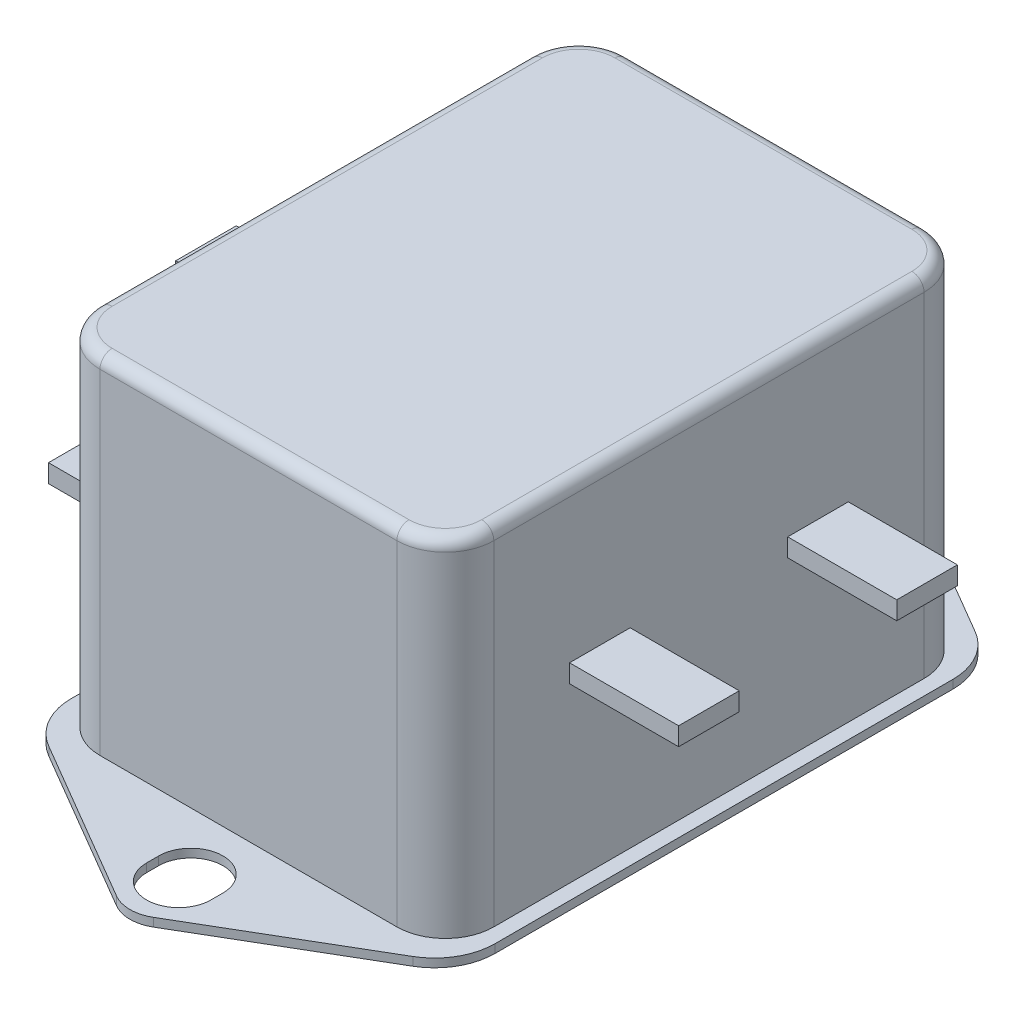
from build123d import *

# Parameters (mm, degrees)
BOSS_EXTRUDE1_DEPTH = 0.7
BOSS_EXTRUDE2_DEPTH = 28.6
SKETCH3_W           = 5
SKETCH3_H           = 1.5
BOSS_EXTRUDE3_DEPTH = 9
SKETCH4_W           = 5
SKETCH4_H           = 1.5
BOSS_EXTRUDE4_DEPTH = 9
FILLET1_R           = 1


with BuildPart() as part:
    # Sketch1 → Boss-Extrude1 (new body)
    with BuildSketch(Plane(origin=(0, 0, 0), x_dir=(1, 0, 0), z_dir=(0, 1, 0))):
        with BuildLine():
            Line((-17.5, 0), (-17.5, 18.884045511))
            ThreePointArc((-17.5, 18.884045511), (-16.837918728, 21.370501041), (-15.027015558, 23.198462316))
            Line((-15.027015558, 23.198462316), (-1.516209335, 31.111934533))
            ThreePointArc((-1.516209335, 31.111934533), (0, 31.523284449), (1.516209335, 31.111934533))
            Line((1.516209335, 31.111934533), (15.027015558, 23.198462316))
            ThreePointArc((15.027015558, 23.198462316), (16.837918728, 21.370501041), (17.5, 18.884045511))
            Line((17.5, 18.884045511), (17.5, 0))
            Line((17.5, 0), (17.5, -18.884045511))
            ThreePointArc((17.5, -18.884045511), (16.837918728, -21.370501041), (15.027015558, -23.198462316))
            Line((15.027015558, -23.198462316), (1.516209335, -31.111934533))
            ThreePointArc((1.516209335, -31.111934533), (0, -31.523284449), (-1.516209335, -31.111934533))
            Line((-1.516209335, -31.111934533), (-15.027015558, -23.198462316))
            ThreePointArc((-15.027015558, -23.198462316), (-16.837918728, -21.370501041), (-17.5, -18.884045511))
            Line((-17.5, -18.884045511), (-17.5, 0))
        make_face()
        with BuildLine():
            Line((2.65, 27.5), (2.65, 26.5))
            ThreePointArc((2.65, 26.5), (0, 23.85), (-2.65, 26.5))
            Line((-2.65, 26.5), (-2.65, 27.5))
            ThreePointArc((-2.65, 27.5), (0, 30.15), (2.65, 27.5))
        make_face(mode=Mode.SUBTRACT)
        with BuildLine():
            Line((2.65, -26.5), (2.65, -27.5))
            ThreePointArc((2.65, -27.5), (0, -30.15), (-2.65, -27.5))
            Line((-2.65, -27.5), (-2.65, -26.5))
            ThreePointArc((-2.65, -26.5), (0, -23.85), (2.65, -26.5))
        make_face(mode=Mode.SUBTRACT)
    extrude(amount=BOSS_EXTRUDE1_DEPTH)

    # Sketch2 → Boss-Extrude2 (add)
    with BuildSketch(Plane(origin=(0, 0.7, 0), x_dir=(1, 0, 0), z_dir=(0, 1, 0))):
        with BuildLine():
            Line((-12.25, 21.75), (12.25, 21.75))
            ThreePointArc((12.25, 21.75), (15.078427125, 20.578427125), (16.25, 17.75))
            Line((16.25, 17.75), (16.25, -17.75))
            ThreePointArc((16.25, -17.75), (15.078427125, -20.578427125), (12.25, -21.75))
            Line((12.25, -21.75), (-12.25, -21.75))
            ThreePointArc((-12.25, -21.75), (-15.078427125, -20.578427125), (-16.25, -17.75))
            Line((-16.25, -17.75), (-16.25, 17.75))
            ThreePointArc((-16.25, 17.75), (-15.078427125, 20.578427125), (-12.25, 21.75))
        make_face()
    extrude(amount=BOSS_EXTRUDE2_DEPTH)

    # Sketch3 → Boss-Extrude3 (add)
    with BuildSketch(Plane.ZY.offset(16.25)):
        with Locations((-10.5, 10)):
            Rectangle(SKETCH3_W, SKETCH3_H)
        with Locations((10.5, 10)):
            Rectangle(SKETCH3_W, SKETCH3_H)
        with Locations((0, 19.18013067)):
            Rectangle(SKETCH3_W, SKETCH3_H)
    extrude(amount=BOSS_EXTRUDE3_DEPTH)

    # Sketch4 → Boss-Extrude4 (add)
    with BuildSketch(Plane(origin=(16.25, 0, 0), x_dir=(0, 0, -1), z_dir=(1, 0, 0))):
        with Locations((-9, 15.7)):
            Rectangle(SKETCH4_W, SKETCH4_H)
        with Locations((9, 15.7)):
            Rectangle(SKETCH4_W, SKETCH4_H)
    extrude(amount=BOSS_EXTRUDE4_DEPTH)

    # Fillet1
    fillet1_edges = [part.edges().sort_by_distance(p)[0] for p in [
        (-15.078427125, 29.3, 20.578427125),
        (0, 29.3, 21.75),
        (15.078427125, 29.3, 20.578427125),
        (16.25, 29.3, 0),
        (15.078427125, 29.3, -20.578427125),
        (0, 29.3, -21.75),
        (-15.078427125, 29.3, -20.578427125),
        (-16.25, 29.3, 0),
    ]]
    fillet(fillet1_edges, radius=FILLET1_R)


solid = part.part
